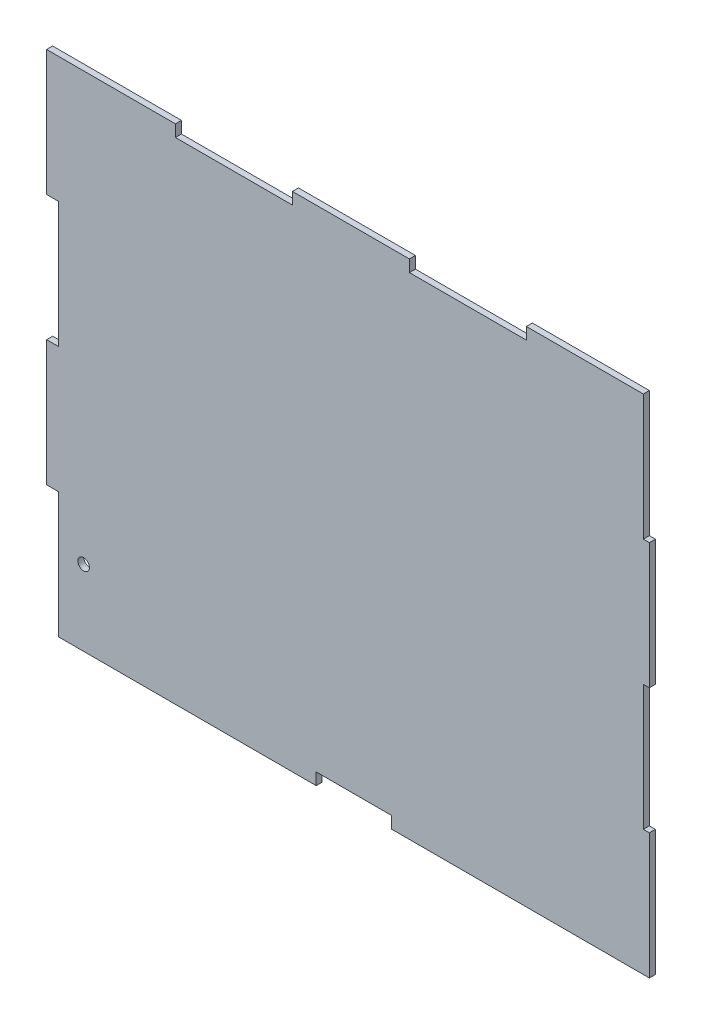
from build123d import *

# Parameters (mm, degrees)
BOSS_EXTRUDE1_DEPTH = 3.048
CUT_EXTRUDE1_REACH  = 5.048
SKETCH2_R           = 2.921


with BuildPart() as part:
    # Sketch1 → Boss-Extrude1 (new body)
    with BuildSketch(Plane.XY):
        Polygon((130.175, 0), (130.175, 5.9944), (168.275, 5.9944), (168.275, 0), (298.45, 0), (298.45, 63.5), (295.402, 63.5), (295.402, 126.929256228), (298.45, 126.929256228), (298.45, 190.429256228), (295.402, 190.429256228), (295.402, 253.929256228), (236.3216, 253.929256228), (236.3216, 247.960256228), (177.2412, 247.960256228), (177.2412, 253.929256228), (118.1608, 253.929256228), (118.1608, 247.960256228), (59.0804, 247.960256228), (59.0804, 253.929256228), (-5.9944, 253.929256228), (-5.9944, 190.5), (0, 190.5), (0, 127), (-5.9944, 127), (-5.9944, 63.5), (0, 63.5), (0, 0), align=None)
    extrude(amount=BOSS_EXTRUDE1_DEPTH)

    # Sketch2 → Cut-Extrude1 (cut, up to next)
    with BuildSketch(Plane.XY.offset(3.048), mode=Mode.PRIVATE) as cut_extrude1_sk1:
        with Locations((12.7, 38.1)):
            Circle(SKETCH2_R)
    cut_extrude1_tool1 = extrude(cut_extrude1_sk1.sketch, amount=-CUT_EXTRUDE1_REACH, mode=Mode.PRIVATE) & part.part
    add(cut_extrude1_tool1.solids().sort_by_distance((12.7, 38.1, 3.048))[0], mode=Mode.SUBTRACT)


solid = part.part
